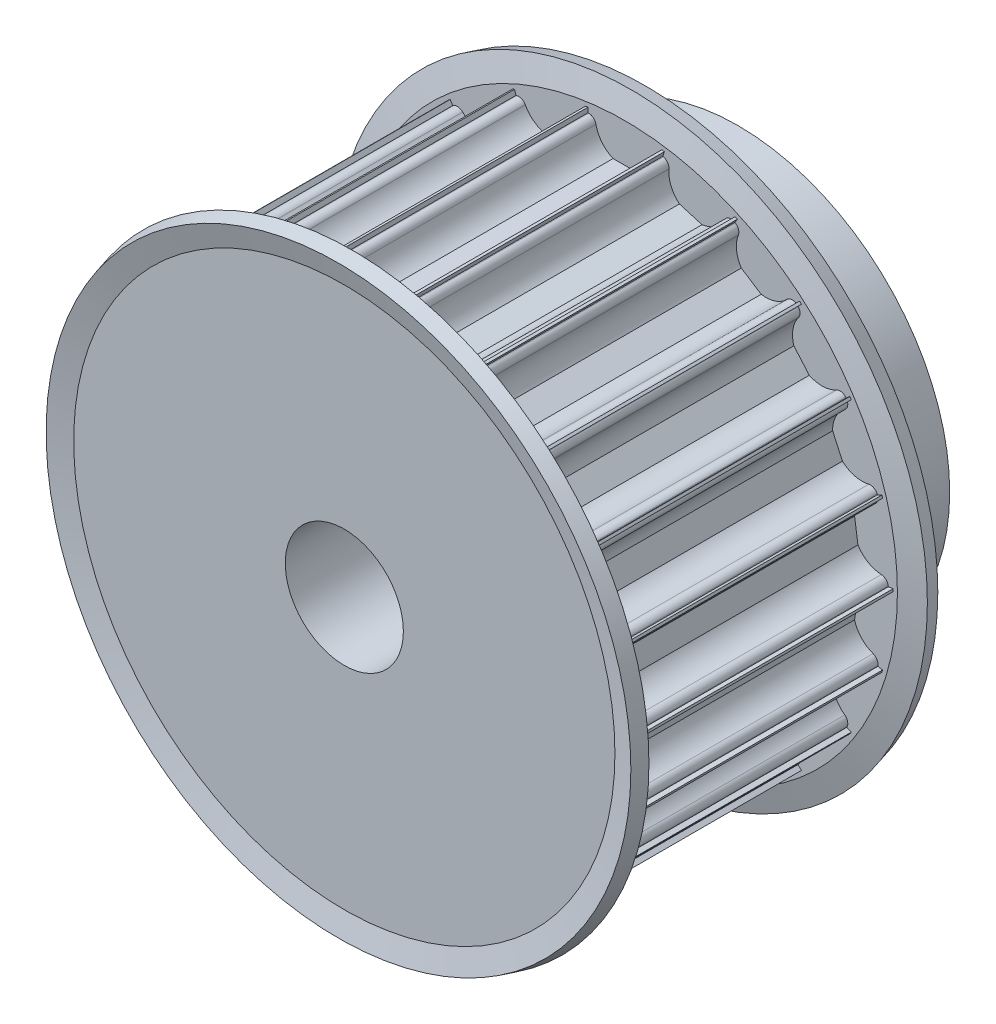
from build123d import *

# Parameters (mm, degrees)
CUT_EXTRUDE1_DEPTH = 30
CIRPATTERN1_COUNT  = 22


with BuildPart() as part:
    # Sketch1 → Revolve1 (revolve)
    with BuildSketch(Plane(origin=(0, 0, 0), x_dir=(0, 0, -1), z_dir=(1, 0, 0))):
        Polygon((0, 6), (40, 6), (40, 21.5), (30, 21.5), (30, 27.25), (0, 27.25), align=None)
    revolve(axis=Axis((0, 0, 0), (0, 0, -1)))

    # Sketch2 → Cut-Extrude1 (cut)
    with BuildSketch(Plane.XY):
        with BuildLine():
            Line((-3.674234614, 26.5), (-3.75, 26.5))
            Line((-3.75, 26.5), (-3.75, 28.5))
            Line((-3.75, 28.5), (3.75, 28.5))
            Line((3.75, 28.5), (3.75, 26.5))
            Line((3.75, 26.5), (3.674234614, 26.5))
            ThreePointArc((3.674234614, 26.5), (3.199892965, 26.330947502), (2.939387691, 25.9))
            ThreePointArc((2.939387691, 25.9), (2.331759211, 24.612435701), (1.198957881, 23.75))
            Line((1.198957881, 23.75), (-1.198957881, 23.75))
            ThreePointArc((-1.198957881, 23.75), (-2.331759211, 24.612435701), (-2.939387691, 25.9))
            ThreePointArc((-2.939387691, 25.9), (-3.199892965, 26.330947502), (-3.674234614, 26.5))
        make_face()
    cut_extrude1 = extrude(amount=-CUT_EXTRUDE1_DEPTH, mode=Mode.SUBTRACT)

    # CirPattern1: Cut-Extrude1 ×22 about axis
    cirpattern1_axis = Axis((0, 0, 0), (0, 0, 1))
    for i in range(1, CIRPATTERN1_COUNT):
        add(cut_extrude1.rotate(cirpattern1_axis, i * 360 / CIRPATTERN1_COUNT), mode=Mode.SUBTRACT)

    # Sketch3 → Revolve2 (revolve)
    with BuildSketch(Plane(origin=(0, 0, 0), x_dir=(0, 0, -1), z_dir=(1, 0, 0))):
        Polygon((30, 21.5), (30, 27.492521254), (30.591966801, 29.701771432), (29.143078062, 30.09), (28.5, 27.69), (28.5, 21.5), align=None)
        Polygon((1.5, 21.5), (0, 21.5), (0, 27.492521254), (-0.591966801, 29.701771432), (0.856921938, 30.09), (1.5, 27.69), align=None)
    revolve(axis=Axis((0, 0, 0), (0, 0, -1)))


solid = part.part
